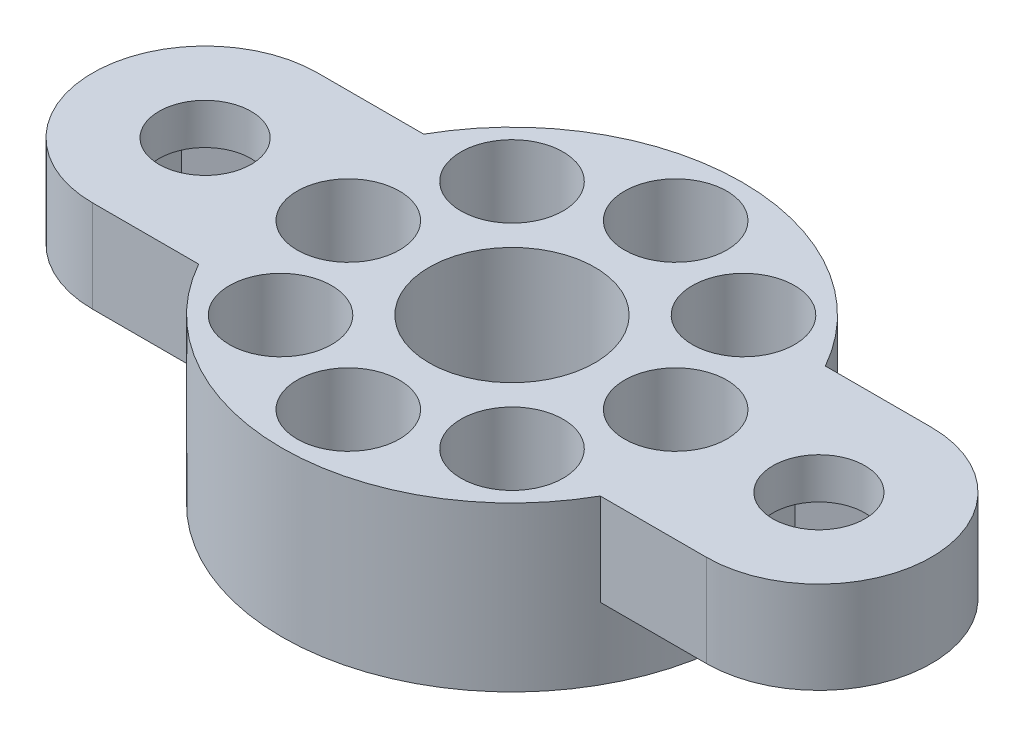
from build123d import *

# Parameters (mm, degrees)
SKETCH1_R           = 11.25
SKETCH1_R_2         = 1.1
SKETCH1_R_3         = 4.05
BOSS_EXTRUDE1_DEPTH = 8
SKETCH2_R           = 2.5
CUT_EXTRUDE1_DEPTH  = 6
SKETCH3_R           = 2.25
BOSS_EXTRUDE2_DEPTH = 4.5
CUT_EXTRUDE2_DEPTH  = 2.5


with BuildPart() as part:
    # Sketch1 → Boss-Extrude1 (new body)
    with BuildSketch(Plane(origin=(0, 0, 0), x_dir=(1, 0, 0), z_dir=(0, 1, 0))):
        Circle(SKETCH1_R)
        with Locations((0, 8)):
            Circle(SKETCH1_R_2, mode=Mode.SUBTRACT)
        with Locations((5.656854249, 5.656854249)):
            Circle(SKETCH1_R_2, mode=Mode.SUBTRACT)
        with Locations((8, 0)):
            Circle(SKETCH1_R_2, mode=Mode.SUBTRACT)
        with Locations((5.656854249, -5.656854249)):
            Circle(SKETCH1_R_2, mode=Mode.SUBTRACT)
        with Locations((0, -8)):
            Circle(SKETCH1_R_2, mode=Mode.SUBTRACT)
        with Locations((-5.656854249, -5.656854249)):
            Circle(SKETCH1_R_2, mode=Mode.SUBTRACT)
        with Locations((-8, 0)):
            Circle(SKETCH1_R_2, mode=Mode.SUBTRACT)
        with Locations((-5.656854249, 5.656854249)):
            Circle(SKETCH1_R_2, mode=Mode.SUBTRACT)
        Circle(SKETCH1_R_3, mode=Mode.SUBTRACT)
    extrude(amount=BOSS_EXTRUDE1_DEPTH)

    # Sketch2 → Cut-Extrude1 (cut)
    with BuildSketch(Plane(origin=(0, 8, 0), x_dir=(1, 0, 0), z_dir=(0, 1, 0))):
        with Locations((0, 8)):
            Circle(SKETCH2_R)
        with Locations((5.656854249, 5.656854249)):
            Circle(SKETCH2_R)
        with Locations((8, 0)):
            Circle(SKETCH2_R)
        with Locations((5.656854249, -5.656854249)):
            Circle(SKETCH2_R)
        with Locations((0, -8)):
            Circle(SKETCH2_R)
        with Locations((-5.656854249, -5.656854249)):
            Circle(SKETCH2_R)
        with Locations((-8, 0)):
            Circle(SKETCH2_R)
        with Locations((-5.656854249, 5.656854249)):
            Circle(SKETCH2_R)
    extrude(amount=-CUT_EXTRUDE1_DEPTH, mode=Mode.SUBTRACT)

    # Sketch3 → Boss-Extrude2 (add)
    with BuildSketch(Plane(origin=(0, 8, 0), x_dir=(1, 0, 0), z_dir=(0, 1, 0))):
        with BuildLine():
            Line((-15, 5.5), (-9.813893213, 5.5))
            ThreePointArc((-9.813893213, 5.5), (-11.25, 0), (-9.813893213, -5.5))
            Line((-9.813893213, -5.5), (-15, -5.5))
            ThreePointArc((-15, -5.5), (-20.5, 0), (-15, 5.5))
        make_face()
        with Locations((-15, 0)):
            Circle(SKETCH3_R, mode=Mode.SUBTRACT)
        with BuildLine():
            Line((9.813893213, 5.5), (15, 5.5))
            ThreePointArc((15, 5.5), (20.5, 0), (15, -5.5))
            Line((15, -5.5), (9.813893213, -5.5))
            ThreePointArc((9.813893213, -5.5), (11.25, 0), (9.813893213, 5.5))
        make_face()
        with Locations((15, 0)):
            Circle(SKETCH3_R, mode=Mode.SUBTRACT)
    extrude(amount=-BOSS_EXTRUDE2_DEPTH)

    # Sketch4 → Cut-Extrude2 (cut)
    with BuildSketch(Plane.XZ.offset(-3.5)):
        Polygon((-15, 3.175426481), (-17.75, 1.58771324), (-17.75, -1.58771324), (-15, -3.175426481), (-12.25, -1.58771324), (-12.25, 1.58771324), align=None)
        Polygon((12.25, 1.58771324), (15, 3.175426481), (17.75, 1.58771324), (17.75, -1.58771324), (15, -3.175426481), (12.25, -1.58771324), align=None)
    extrude(amount=-CUT_EXTRUDE2_DEPTH, mode=Mode.SUBTRACT)


solid = part.part
